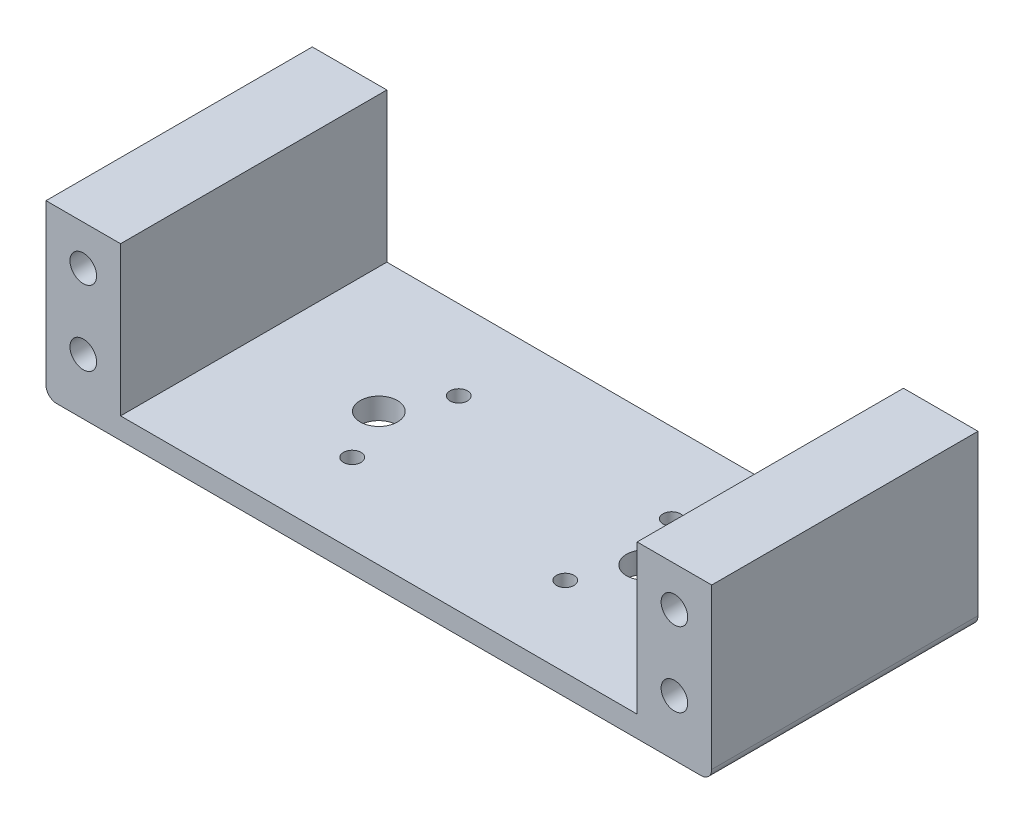
from build123d import *

# Parameters (mm, degrees)
SKETCH1_W           = 125
SKETCH1_H           = 50
BOSS_EXTRUDE1_DEPTH = 4
SKETCH2_W           = 14
SKETCH2_H           = 50
BOSS_EXTRUDE2_DEPTH = 28
SKETCH3_R           = 2.5
CUT_EXTRUDE1_DEPTH  = 4.78
SKETCH4_R           = 1.65
SKETCH4_R_2         = 3.5
CUT_EXTRUDE2_DEPTH  = 33
FILLET1_R           = 2


with BuildPart() as part:
    # Sketch1 → Boss-Extrude1 (new body)
    with BuildSketch(Plane(origin=(0, 0, 0), x_dir=(1, 0, 0), z_dir=(0, 1, 0))):
        with Locations((62.5, 25)):
            Rectangle(SKETCH1_W, SKETCH1_H)
    extrude(amount=BOSS_EXTRUDE1_DEPTH)

    # Sketch2 → Boss-Extrude2 (add)
    with BuildSketch(Plane(origin=(0, 4, 0), x_dir=(1, 0, 0), z_dir=(0, 1, 0))):
        with Locations((7, 25)):
            Rectangle(SKETCH2_W, SKETCH2_H)
        with Locations((118, 25)):
            Rectangle(SKETCH2_W, SKETCH2_H)
    extrude(amount=BOSS_EXTRUDE2_DEPTH)

    # Sketch3 → Cut-Extrude1 (cut)
    with BuildSketch(Plane.XY):
        with Locations((7, 24.5)):
            Circle(SKETCH3_R)
        with Locations((7, 10.5)):
            Circle(SKETCH3_R)
        with Locations((118, 10.5)):
            Circle(SKETCH3_R)
        with Locations((118, 24.5)):
            Circle(SKETCH3_R)
    cut_extrude1 = extrude(amount=-CUT_EXTRUDE1_DEPTH, mode=Mode.SUBTRACT)

    # Mirror1: Cut-Extrude1 across plane
    add(cut_extrude1.mirror(Plane.XY.offset(-25)), mode=Mode.SUBTRACT)

    # Sketch4 → Cut-Extrude2 (cut, through all)
    with BuildSketch(Plane.XZ):
        with Locations((82.5, -15)):
            Circle(SKETCH4_R)
        with Locations((42.5, -15)):
            Circle(SKETCH4_R)
        with Locations((82.5, -35)):
            Circle(SKETCH4_R)
        with Locations((42.5, -35)):
            Circle(SKETCH4_R)
        with Locations((37.5, -25)):
            Circle(SKETCH4_R_2)
        with Locations((87.5, -25)):
            Circle(SKETCH4_R_2)
    extrude(amount=-CUT_EXTRUDE2_DEPTH, mode=Mode.SUBTRACT)

    # Fillet1
    fillet1_edges = [part.edges().sort_by_distance(p)[0] for p in [
        (125, 0, -25),
        (0, 0, -25),
    ]]
    fillet(fillet1_edges, radius=FILLET1_R)


solid = part.part
